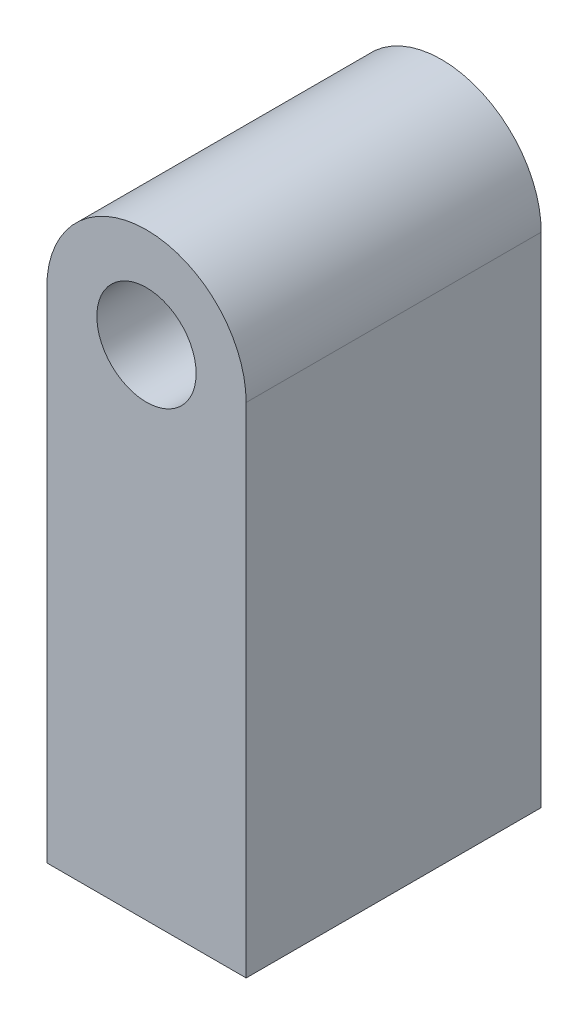
from build123d import *

# Parameters (mm, degrees)
BOSS_EXTRUDE1_DEPTH         = 9.398
F_1_4_0_249_DOWEL_HOLE1_D   = 6.3246
F_1_4_20_TAPPED_HOLE1_D     = 5.1054
F_1_4_20_TAPPED_HOLE1_DEPTH = 13.335
F_1_4_20_TAPPED_HOLE1_TIP   = 1.533816902


with BuildPart() as part:
    # Sketch2 → Boss-Extrude1 (new body, symmetric)
    with BuildSketch(Plane.XY):
        with BuildLine():
            Line((-6.35, 0), (6.35, 0))
            Line((6.35, 0), (6.35, 31.75))
            ThreePointArc((6.35, 31.75), (0, 38.1), (-6.35, 31.75))
            Line((-6.35, 31.75), (-6.35, 0))
        make_face()
    extrude(amount=BOSS_EXTRUDE1_DEPTH, both=True)

    # 1/4 (0.249) Dowel Hole1 (through all)
    with Locations(Plane.XY.offset(9.398)):
        with Locations((0, 31.75)):
            Hole(F_1_4_0_249_DOWEL_HOLE1_D / 2)

    # 1/4-20 Tapped Hole1
    with Locations(Plane(origin=(0, 0, 0), x_dir=(-1, 0, 0), z_dir=(0, -1, 0))):
        with Locations((0, 0)):
            Hole(F_1_4_20_TAPPED_HOLE1_D / 2, depth=F_1_4_20_TAPPED_HOLE1_DEPTH)
            with Locations((0, 0, -(F_1_4_20_TAPPED_HOLE1_DEPTH + F_1_4_20_TAPPED_HOLE1_TIP / 2))):  # 118° drill point
                Cone(0, F_1_4_20_TAPPED_HOLE1_D / 2, F_1_4_20_TAPPED_HOLE1_TIP, mode=Mode.SUBTRACT)


solid = part.part
